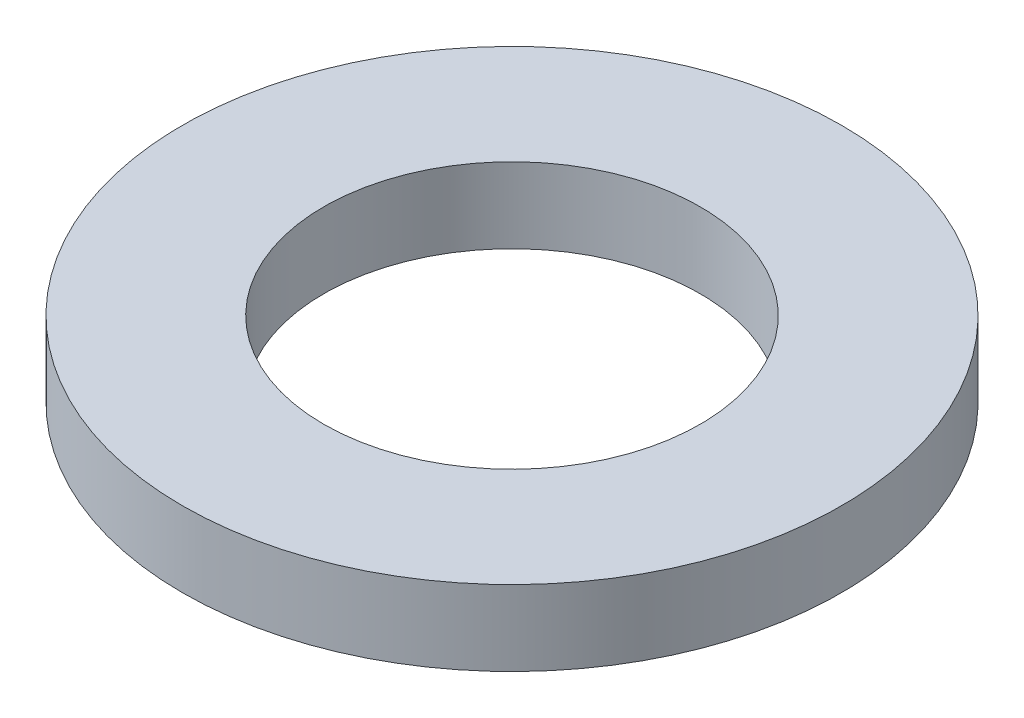
from build123d import *

# Parameters (mm, degrees)
SKETCH1_R           = 7
SKETCH1_R_2         = 4
BOSS_EXTRUDE1_DEPTH = 1.6


with BuildPart() as part:
    # Sketch1 → Boss-Extrude1 (new body)
    with BuildSketch(Plane(origin=(0, 0, 0), x_dir=(1, 0, 0), z_dir=(0, 1, 0))):
        Circle(SKETCH1_R)
        Circle(SKETCH1_R_2, mode=Mode.SUBTRACT)
    extrude(amount=BOSS_EXTRUDE1_DEPTH)


solid = part.part
